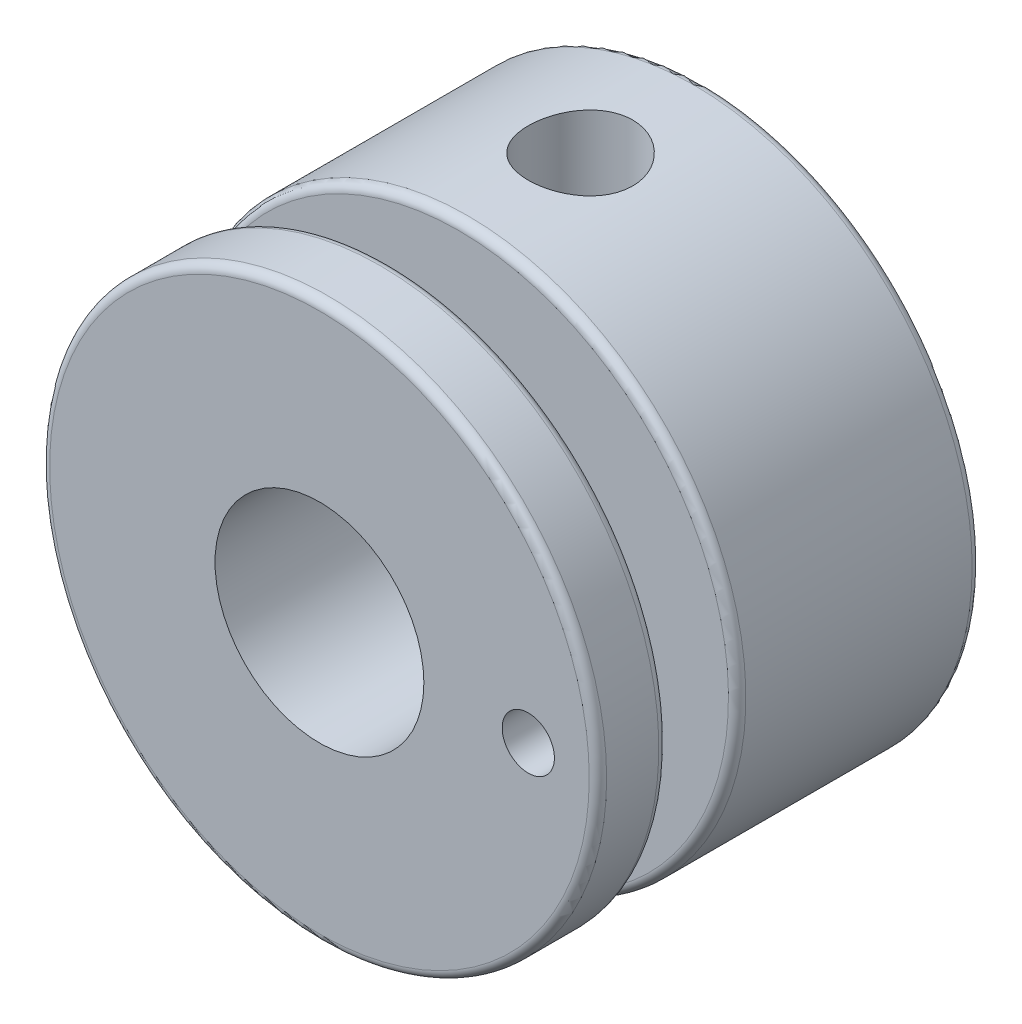
from build123d import *

# Parameters (mm, degrees)
SKETCH1_R           = 8
BOSS_EXTRUDE1_DEPTH = 11
SKETCH2_W           = 2
SKETCH2_H           = 3
CUT_EXTRUDE1_REACH  = 12.5
CUT_EXTRUDE1_START  = 2.5
SKETCH5_R           = 1.5
CUT_EXTRUDE2_REACH  = 13
SKETCH6_R           = 3
FILLET3_R           = 0.25
FILLET4_R           = 0.25
FILLET5_R           = 0.25
CUT_EXTRUDE3_REACH  = 13
SKETCH7_R           = 0.75


with BuildPart() as part:
    # Sketch1 → Boss-Extrude1 (new body)
    with BuildSketch(Plane.XY):
        Circle(SKETCH1_R)
    extrude(amount=BOSS_EXTRUDE1_DEPTH)

    # Sketch2 → Cut-Revolve2 (revolve, cut)
    with BuildSketch(Plane(origin=(0, 0, 0), x_dir=(0, 0, -1), z_dir=(1, 0, 0))):
        with Locations((-8, 6.5)):
            Rectangle(SKETCH2_W, SKETCH2_H)
    revolve(axis=Axis((0, 0, -5.249485175), (0, 0, 1)), mode=Mode.SUBTRACT)

    # Sketch5 → Cut-Extrude1 (cut, up to next)
    with BuildSketch(Plane(origin=(0, 0, 0), x_dir=(1, 0, 0), z_dir=(0, 1, 0)).offset(CUT_EXTRUDE1_START), mode=Mode.PRIVATE) as cut_extrude1_sk1:
        with Locations((0, -3.5)):
            Circle(SKETCH5_R)
    cut_extrude1_tool1 = extrude(cut_extrude1_sk1.sketch, amount=CUT_EXTRUDE1_REACH, mode=Mode.PRIVATE) & part.part
    add(cut_extrude1_tool1.solids().sort_by_distance((0, 2.5, 3.5))[0], mode=Mode.SUBTRACT)

    # Sketch6 → Cut-Extrude2 (cut, up to next)
    with BuildSketch(Plane.XY, mode=Mode.PRIVATE) as cut_extrude2_sk1:
        Circle(SKETCH6_R)
    cut_extrude2_tool1 = extrude(cut_extrude2_sk1.sketch, amount=CUT_EXTRUDE2_REACH, mode=Mode.PRIVATE) & part.part
    add(cut_extrude2_tool1.solids().sort_by_distance((0, 0, 0))[0], mode=Mode.SUBTRACT)

    # Fillet3
    fillet3_edges = [part.edges().sort_by_distance(p)[0] for p in [
        (-8, 0, 9),
    ]]
    fillet(fillet3_edges, radius=FILLET3_R)

    # Fillet4
    fillet4_edges = [part.edges().sort_by_distance(p)[0] for p in [
        (-8, 0, 7),
    ]]
    fillet(fillet4_edges, radius=FILLET4_R)

    # Fillet5
    fillet5_edges = [part.edges().sort_by_distance(p)[0] for p in [
        (-8, 0, 0),
        (-8, 0, 11),
    ]]
    fillet(fillet5_edges, radius=FILLET5_R)

    # Sketch7 → Cut-Extrude3 (cut, up to next)
    with BuildSketch(Plane.XY.offset(11), mode=Mode.PRIVATE) as cut_extrude3_sk1:
        with Locations((6, 0)):
            Circle(SKETCH7_R)
    cut_extrude3_tool1 = extrude(cut_extrude3_sk1.sketch, amount=-CUT_EXTRUDE3_REACH, mode=Mode.PRIVATE) & part.part
    add(cut_extrude3_tool1.solids().sort_by_distance((6, 0, 11))[0], mode=Mode.SUBTRACT)


solid = part.part
